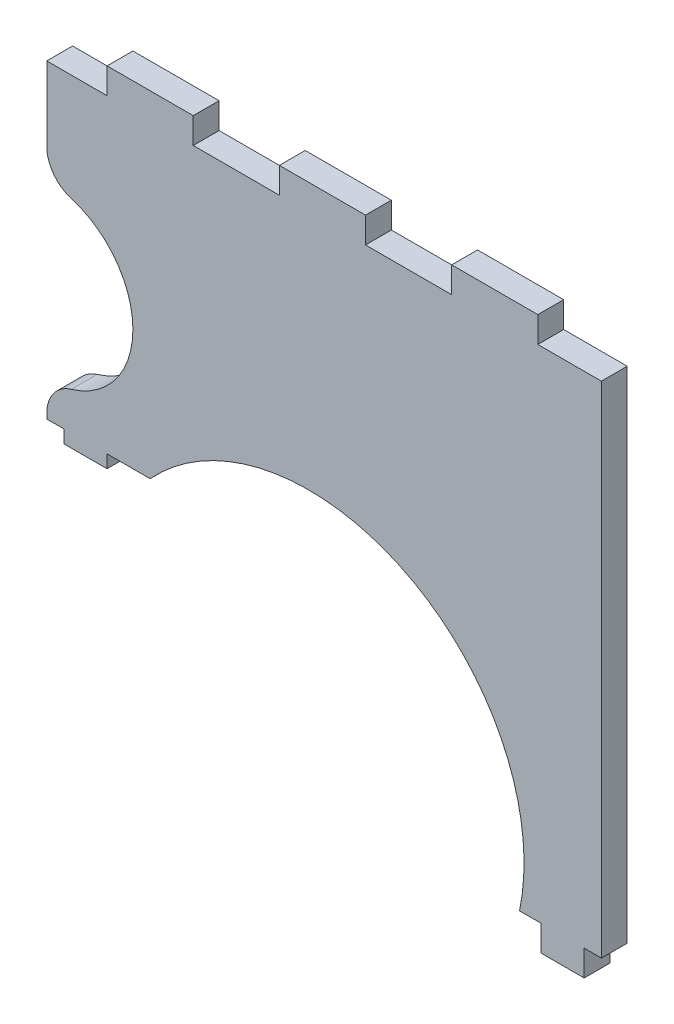
from build123d import *

# Parameters (mm, degrees)
SALIENTE_EXTRUIR1_DEPTH = 3
CORTAR_EXTRUIR1_DEPTH   = 3
REDONDEO1_R             = 4


with BuildPart() as part:
    # Croquis1 → Saliente-Extruir1 (new body)
    with BuildSketch(Plane.XY):
        with BuildLine():
            Line((0, 0), (0, -3))
            Line((0, -3), (-5, -3))
            Line((-5, -3), (-5, 0))
            Line((-5, 0), (-7.5, 0))
            ThreePointArc((-7.5, 0), (-20.567061666, 27.319617989), (-50.38, 22))
            Line((-50.38, 22), (-55.38, 22))
            Line((-55.38, 22), (-55.38, 20.5))
            Line((-55.38, 20.5), (-60.38, 20.5))
            Line((-60.38, 20.5), (-60.38, 22))
            Line((-60.38, 22), (-62.38, 22))
            Line((-62.38, 22), (-62.38, 58))
            Line((-62.38, 58), (-55.38, 58))
            Line((-55.38, 58), (-55.38, 61))
            Line((-55.38, 61), (-45.38, 61))
            Line((-45.38, 61), (-45.38, 58))
            Line((-45.38, 58), (-35.38, 58))
            Line((-35.38, 58), (-35.38, 61))
            Line((-35.38, 61), (-25.38, 61))
            Line((-25.38, 61), (-25.38, 58))
            Line((-25.38, 58), (-15.38, 58))
            Line((-15.38, 58), (-15.38, 61))
            Line((-15.38, 61), (-5.38, 61))
            Line((-5.38, 61), (-5.38, 58))
            Line((-5.38, 58), (2, 58))
            Line((2, 58), (2, 0))
            Line((2, 0), (0, 0))
        make_face()
    extrude(amount=SALIENTE_EXTRUIR1_DEPTH)

    # Croquis2 → Cortar-Extruir1 (cut)
    with BuildSketch(Plane.XY.offset(3)):
        with BuildLine():
            Line((-62.38, 46), (-62.38, 26))
            ThreePointArc((-62.38, 26), (-52.38, 36), (-62.38, 46))
        make_face()
    extrude(amount=-CORTAR_EXTRUIR1_DEPTH, mode=Mode.SUBTRACT)

    # Redondeo1
    redondeo1_edges = [part.edges().sort_by_distance(p)[0] for p in [
        (-62.38, 46, 1.5),
        (-62.38, 26, 1.5),
    ]]
    fillet(redondeo1_edges, radius=REDONDEO1_R)


solid = part.part
